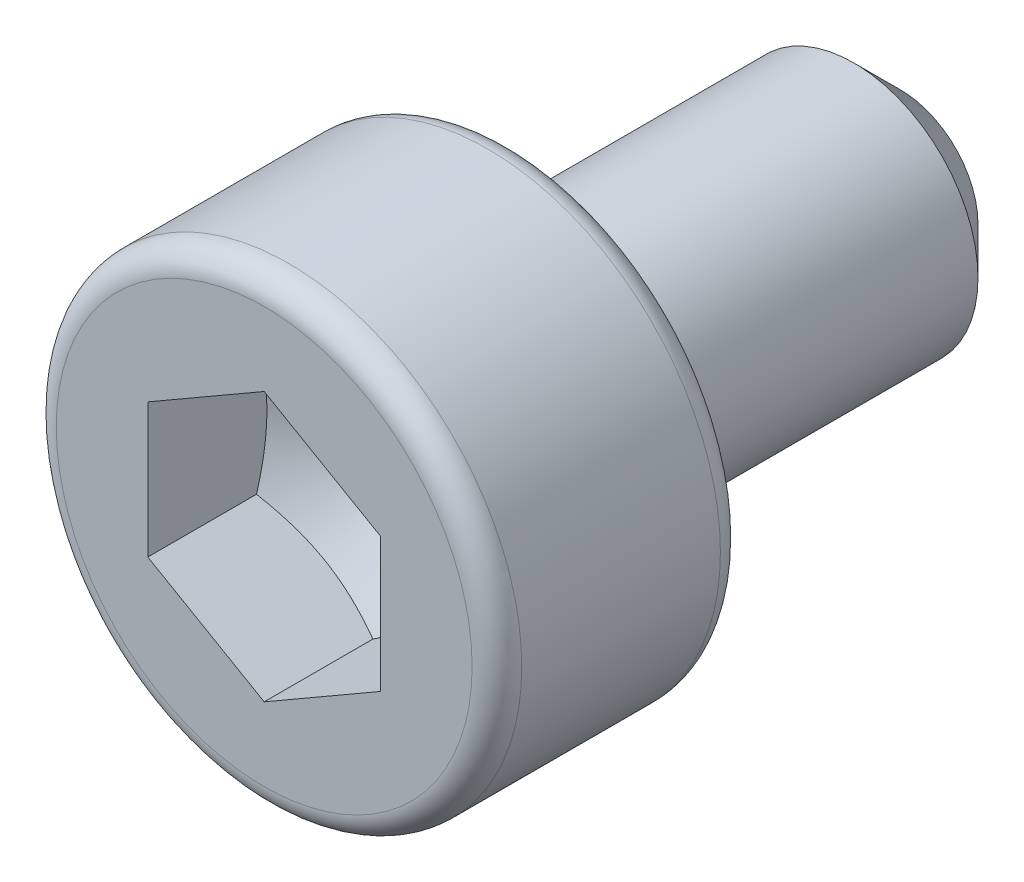
from build123d import *

# Parameters (mm, degrees)
CHAMFERROD_SIZE = 0.3
FILLETHEAD_R    = 0.16
HEXHEAD_DEPTH   = 0.7
HEXHEAD2_DEPTH  = 0.55463
FILLET1_R       = 0.1


with BuildPart() as part:
    # Sketch1 → RevolveBase (revolve)
    with BuildSketch(Plane(origin=(0, 0, 0), x_dir=(0, 0, -1), z_dir=(1, 0, 0))):
        Polygon((0, 0), (0, 1.5), (1.6, 1.5), (1.6, 0.8), (4.1, 0.8), (4.1, 0), align=None)
    revolve(axis=Axis((0, 0, 0), (0, 0, -1)))

    # ChamferRod
    chamferrod_edges = [part.edges().sort_by_distance(p)[0] for p in [
        (0, -0.8, -4.1),
    ]]
    chamfer(chamferrod_edges, length=CHAMFERROD_SIZE)

    # FilletHead
    fillethead_edges = [part.edges().sort_by_distance(p)[0] for p in [
        (0, -1.5, -1.6),
        (0, -1.5, 0),
    ]]
    fillet(fillethead_edges, radius=FILLETHEAD_R)

    # Sketch2 → HexHead (cut)
    with BuildSketch(Plane.XY):
        Polygon((0, 0.866025404), (-0.75, 0.433012702), (-0.75, -0.433012702), (0, -0.866025404), (0.75, -0.433012702), (0.75, 0.433012702), align=None)
    extrude(amount=-HEXHEAD_DEPTH, mode=Mode.SUBTRACT)

    # Sketch3 → HexHead2 (cut)
    with BuildSketch(Plane.XY.offset(-0.7)):
        Polygon((0, 0.866025404), (-0.75, 0.433012702), (-0.75, -0.433012702), (0, -0.866025404), (0.75, -0.433012702), (0.75, 0.433012702), align=None)
    extrude(amount=-HEXHEAD2_DEPTH, mode=Mode.SUBTRACT)

    # Sketch4 → RevolveHexHead (revolve)
    with BuildSketch(Plane(origin=(0, 0, 0), x_dir=(0, 0, -1), z_dir=(1, 0, 0))):
        Polygon((1.20043278, 0), (1.254629995, 0), (1.254629995, 0.866775), (0.7, 0.866775), align=None)
    revolve(axis=Axis((0, 0, 0), (0, 0, -1)))

    # Fillet1
    fillet1_edges = [part.edges().sort_by_distance(p)[0] for p in [
        (0, -0.8, -1.6),
    ]]
    fillet(fillet1_edges, radius=FILLET1_R)


solid = part.part
